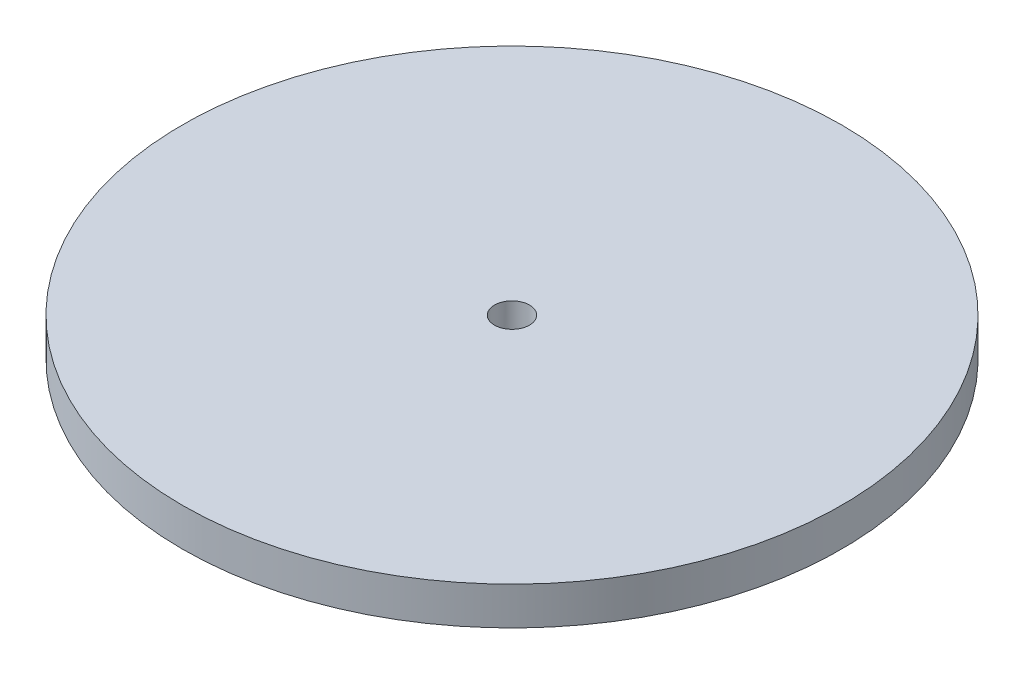
from build123d import *

# Parameters (mm, degrees)
SKETCH1_R           = 83.82
BOSS_EXTRUDE1_DEPTH = 4.826
SKETCH3_R           = 4.445
CUT_EXTRUDE1_DEPTH  = 9.652


with BuildPart() as part:
    # Sketch1 → Boss-Extrude1 (new body, symmetric)
    with BuildSketch(Plane(origin=(0, 0, 0), x_dir=(1, 0, 0), z_dir=(0, 1, 0))):
        Circle(SKETCH1_R)
    extrude(amount=BOSS_EXTRUDE1_DEPTH, both=True)

    # Sketch2 → Cut-Revolve1 (revolve, cut)
    with BuildSketch(Plane.XY):
        with BuildLine():
            Line((0, -4.826), (-19.2970404, -4.826))
            ThreePointArc((-19.2970404, -4.826), (-9.985310315, -2.33207385), (-0.381787908, -1.495209354))
            Line((-0.381787908, -1.495209354), (0, -1.495209354))
            Line((0, -1.495209354), (0, -4.826))
        make_face()
    revolve(axis=Axis((0, -18.327530441, 0), (0, 1, 0)), mode=Mode.SUBTRACT)

    # Sketch3 → Cut-Extrude1 (cut)
    with BuildSketch(Plane(origin=(0, 4.826, 0), x_dir=(1, 0, 0), z_dir=(0, 1, 0))):
        Circle(SKETCH3_R)
    extrude(amount=-CUT_EXTRUDE1_DEPTH, mode=Mode.SUBTRACT)


solid = part.part
